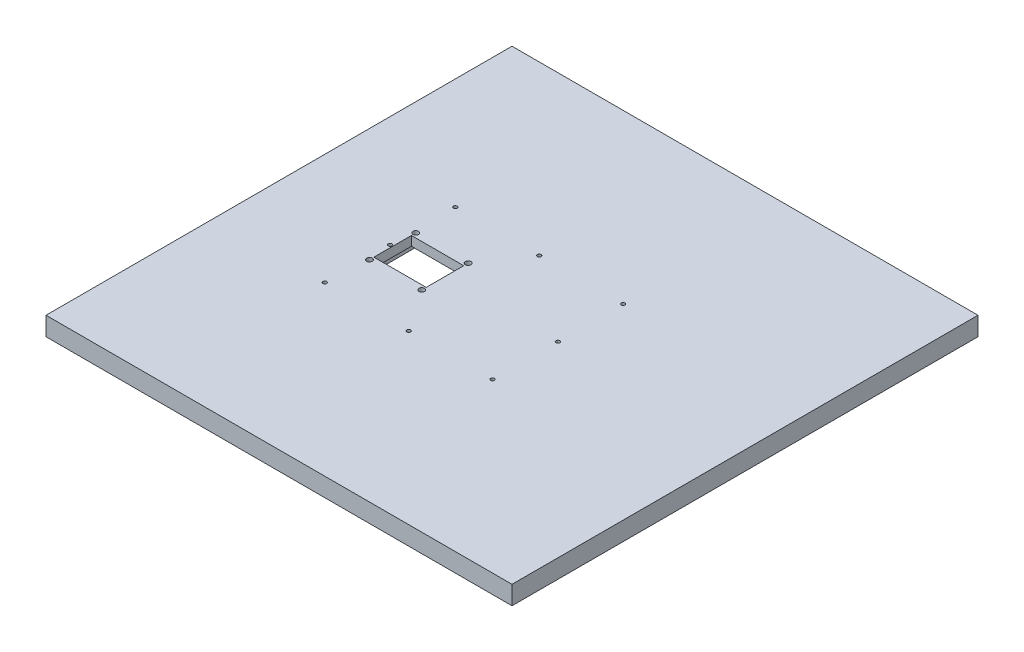
from build123d import *

# Parameters (mm, degrees)
SKETCH1_W           = 500
SKETCH1_H           = 500
SKETCH1_R           = 3
BOSS_EXTRUDE1_DEPTH = 20
SKETCH2_W           = 56.144113512
SKETCH2_H           = 40.288527928
CUT_EXTRUDE2_DEPTH  = 21
SKETCH3_W           = 69.209848312
SKETCH3_H           = 67.559185152
CUT_EXTRUDE3_DEPTH  = 10
SKETCH4_R           = 2
CUT_EXTRUDE4_DEPTH  = 21


with BuildPart() as part:
    # Sketch1 → Boss-Extrude1 (new body)
    with BuildSketch(Plane(origin=(0, 0, 0), x_dir=(1, 0, 0), z_dir=(0, 1, 0))):
        Rectangle(SKETCH1_W, SKETCH1_H)
        with Locations((-128.072056756, 24.863821699)):
            Circle(SKETCH1_R, mode=Mode.SUBTRACT)
        with Locations((-71.927943244, 24.863821699)):
            Circle(SKETCH1_R, mode=Mode.SUBTRACT)
        with Locations((-71.927943244, -24.863821699)):
            Circle(SKETCH1_R, mode=Mode.SUBTRACT)
        with Locations((-128.072056756, -24.863821699)):
            Circle(SKETCH1_R, mode=Mode.SUBTRACT)
    extrude(amount=BOSS_EXTRUDE1_DEPTH)

    # Sketch2 → Cut-Extrude2 (cut, through all)
    with BuildSketch(Plane(origin=(0, 20, 0), x_dir=(1, 0, 0), z_dir=(0, 1, 0))):
        with Locations((-100, 0)):
            Rectangle(SKETCH2_W, SKETCH2_H)
    extrude(amount=-CUT_EXTRUDE2_DEPTH, mode=Mode.SUBTRACT)

    # Sketch3 → Cut-Extrude3 (cut)
    with BuildSketch(Plane.XZ):
        with Locations((-100, 0)):
            Rectangle(SKETCH3_W, SKETCH3_H)
    extrude(amount=-CUT_EXTRUDE3_DEPTH, mode=Mode.SUBTRACT)

    # Sketch4 → Cut-Extrude4 (cut, through all)
    with BuildSketch(Plane(origin=(0, 20, 0), x_dir=(1, 0, 0), z_dir=(0, 1, 0))):
        with Locations((-130.814569141, 70)):
            Circle(SKETCH4_R)
        with Locations((49.185430859, 70)):
            Circle(SKETCH4_R)
        with Locations((-40.814569141, 70)):
            Circle(SKETCH4_R)
        with Locations((-130.814569141, -70)):
            Circle(SKETCH4_R)
        with Locations((-40.814569141, -70)):
            Circle(SKETCH4_R)
        with Locations((49.185430859, -70)):
            Circle(SKETCH4_R)
        with Locations((49.185430859, 0)):
            Circle(SKETCH4_R)
        with Locations((-130.814569141, 0)):
            Circle(SKETCH4_R)
    extrude(amount=-CUT_EXTRUDE4_DEPTH, mode=Mode.SUBTRACT)


solid = part.part
